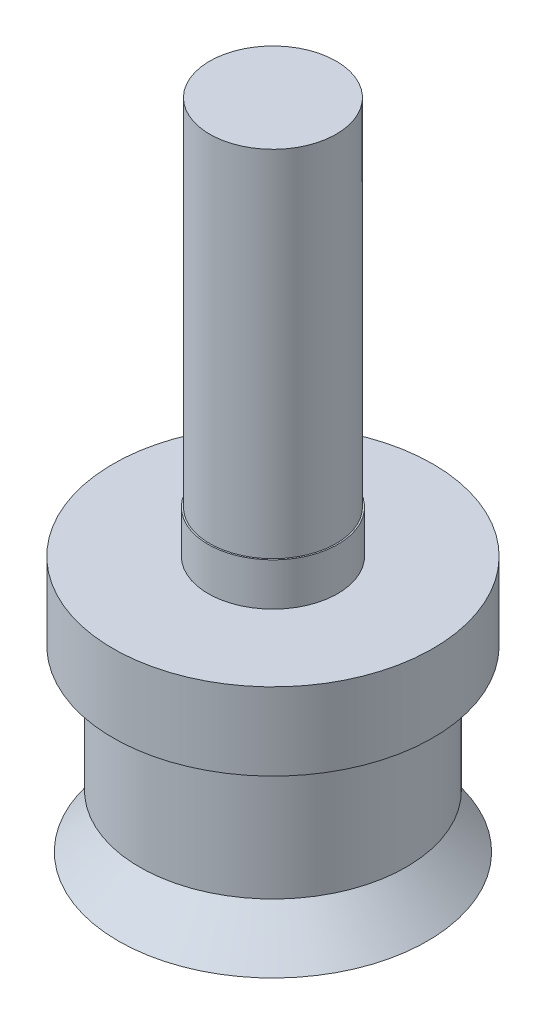
from build123d import *


with BuildPart() as part:
    # Croquis1 → Revolución1 (revolve)
    with BuildSketch(Plane.XY):
        Polygon((0, 14.9), (-2.375, 14.9), (-2.375, 1.6), (-2.43, 1.6), (-2.43, 0), (-6, 0), (-6, -2.9), (-5, -2.9), (-5, -7.6), (-3.5, -7.6), (-5.8, -9.6), (-1.5, -9.6), (-1.5, 2.4), (0, 2.4), align=None)
    revolve(axis=Axis((0, -18.118960647, 0), (0, 1, 0)))


solid = part.part
